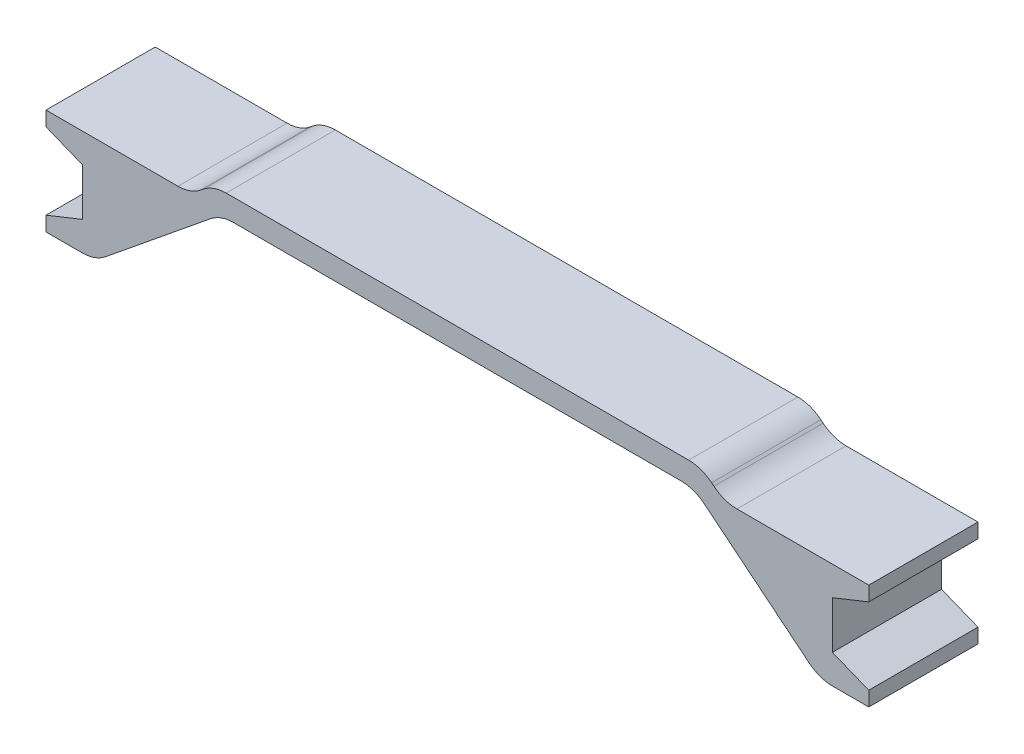
from build123d import *

# Parameters (mm, degrees)
BOSS_EXTRUDE1_DEPTH = 15


with BuildPart() as part:
    # Sketch1 → Boss-Extrude1 (new body)
    with BuildSketch(Plane.XY):
        with BuildLine():
            Line((30.739596692, -3), (-30.739596692, -3))
            ThreePointArc((-30.739596692, -3), (-32.414147122, -3.288749544), (-33.895287282, -4.121647657))
            Line((-33.895287282, -4.121647657), (-48.34430941, -15.878352343))
            ThreePointArc((-48.34430941, -15.878352343), (-49.82544957, -16.711250456), (-51.5, -17))
            Line((-51.5, -17), (-56.5, -17))
            Line((-56.5, -17), (-56.5, -15))
            Line((-56.5, -15), (-51.5, -13))
            Line((-51.5, -13), (-51.5, -6.5))
            Line((-51.5, -6.5), (-56.5, -4.5))
            Line((-56.5, -4.5), (-56.5, -2.5))
            Line((-56.5, -2.5), (-38.387912283, -2.5))
            ThreePointArc((-38.387912283, -2.5), (-36.713361853, -2.211250456), (-35.232221692, -1.378352343))
            Line((-35.232221692, -1.378352343), (-34.916730933, -1.121647657))
            ThreePointArc((-34.916730933, -1.121647657), (-33.435590772, -0.288749544), (-31.761040342, 0))
            Line((-31.761040342, 0), (31.761040342, 0))
            ThreePointArc((31.761040342, 0), (33.435590772, -0.288749544), (34.916730933, -1.121647657))
            Line((34.916730933, -1.121647657), (35.232221692, -1.378352343))
            ThreePointArc((35.232221692, -1.378352343), (36.713361853, -2.211250456), (38.387912283, -2.5))
            Line((38.387912283, -2.5), (56.5, -2.5))
            Line((56.5, -2.5), (56.5, -4.5))
            Line((56.5, -4.5), (51.5, -6.5))
            Line((51.5, -6.5), (51.5, -13))
            Line((51.5, -13), (56.5, -15))
            Line((56.5, -15), (56.5, -17))
            Line((56.5, -17), (51.5, -17))
            ThreePointArc((51.5, -17), (49.82544957, -16.711250456), (48.34430941, -15.878352343))
            Line((48.34430941, -15.878352343), (33.895287282, -4.121647657))
            ThreePointArc((33.895287282, -4.121647657), (32.414147122, -3.288749544), (30.739596692, -3))
        make_face()
    extrude(amount=BOSS_EXTRUDE1_DEPTH)


solid = part.part
